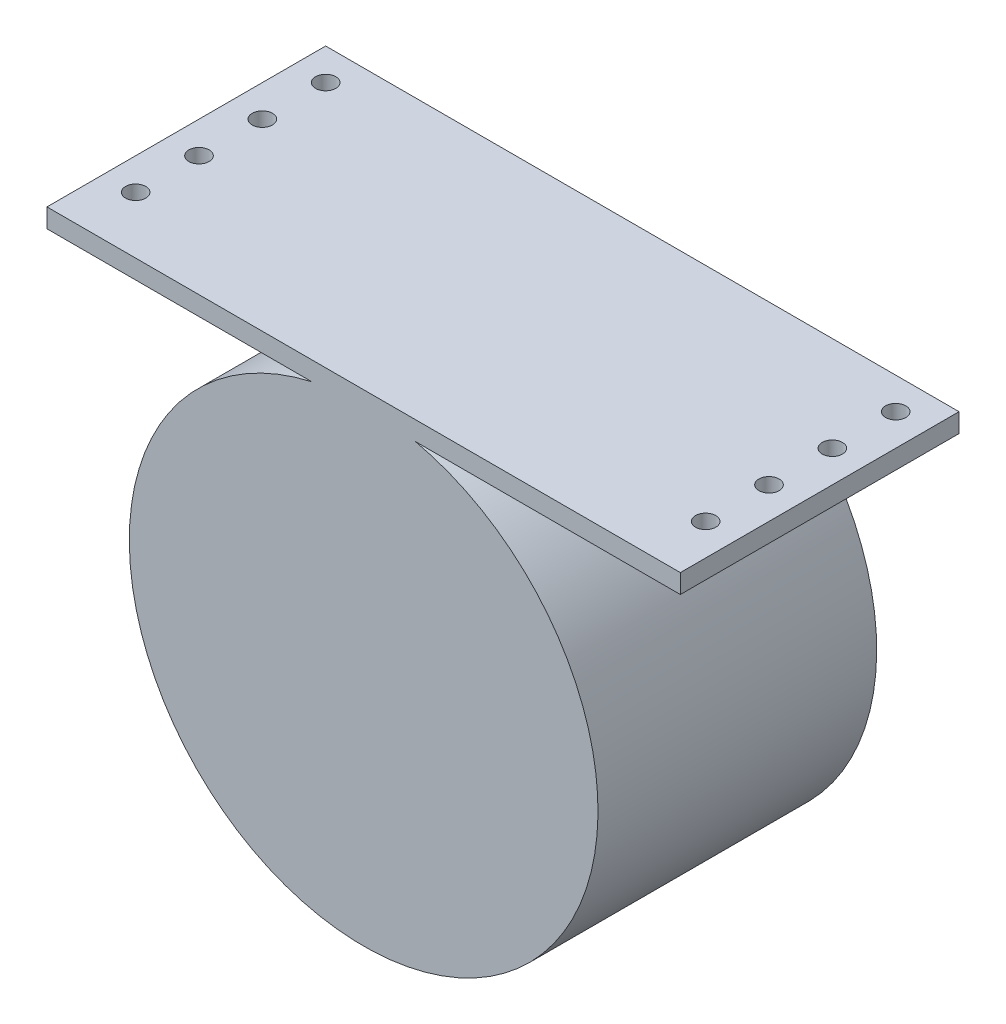
from build123d import *

# Parameters (mm, degrees)
SKETCH_1_R             = 37
SKETCH_1_W             = 100
SKETCH_1_H             = 3
EXTRUDE_1_DEPTH        = 44
SKETCH_2_R             = 34
CUT_EXTRUDE_1_DEPTH    = 40
SKETCH_4_R             = 1.6
CUT_EXTRUDE_2_DEPTH    = 10
PATTERN_LINEAR_1_COUNT = 2
PATTERN_LINEAR_1_PITCH = 90


with BuildPart() as part:
    # ｽｹｯﾁ1 → ﾎﾞｽ - 押し出し1 (new body)
    with BuildSketch(Plane.XY):
        with Locations((-5.795339113, 4.185414542)):
            Circle(SKETCH_1_R)
        with Locations((-5.795339113, 41.771570891)):
            Rectangle(SKETCH_1_W, SKETCH_1_H)
    extrude(amount=EXTRUDE_1_DEPTH)

    # ｽｹｯﾁ2 → ｶｯﾄ - 押し出し1 (cut)
    with BuildSketch(Plane(origin=(0, 0, 0), x_dir=(-1, 0, 0), z_dir=(0, 0, -1))):
        with Locations((5.795339113, 4.185414542)):
            Circle(SKETCH_2_R)
    extrude(amount=-CUT_EXTRUDE_1_DEPTH, mode=Mode.SUBTRACT)

    # ｽｹｯﾁ4 → ｶｯﾄ - 押し出し2 (cut)
    with BuildSketch(Plane(origin=(0, 43.271570891, 0), x_dir=(1, 0, 0), z_dir=(0, 1, 0))):
        with Locations((-50.795339113, -5)):
            Circle(SKETCH_4_R)
        with Locations((-50.795339113, -15)):
            Circle(SKETCH_4_R)
        with Locations((-50.795339113, -25)):
            Circle(SKETCH_4_R)
        with Locations((-50.795339113, -35)):
            Circle(SKETCH_4_R)
    cut_extrude_2 = extrude(amount=-CUT_EXTRUDE_2_DEPTH, mode=Mode.SUBTRACT)

    # 直線ﾊﾟﾀｰﾝ1: ｶｯﾄ - 押し出し2 ×2
    with Locations(*[(i * PATTERN_LINEAR_1_PITCH, 0, 0) for i in range(1, PATTERN_LINEAR_1_COUNT)]):
        add(cut_extrude_2, mode=Mode.SUBTRACT)


solid = part.part
